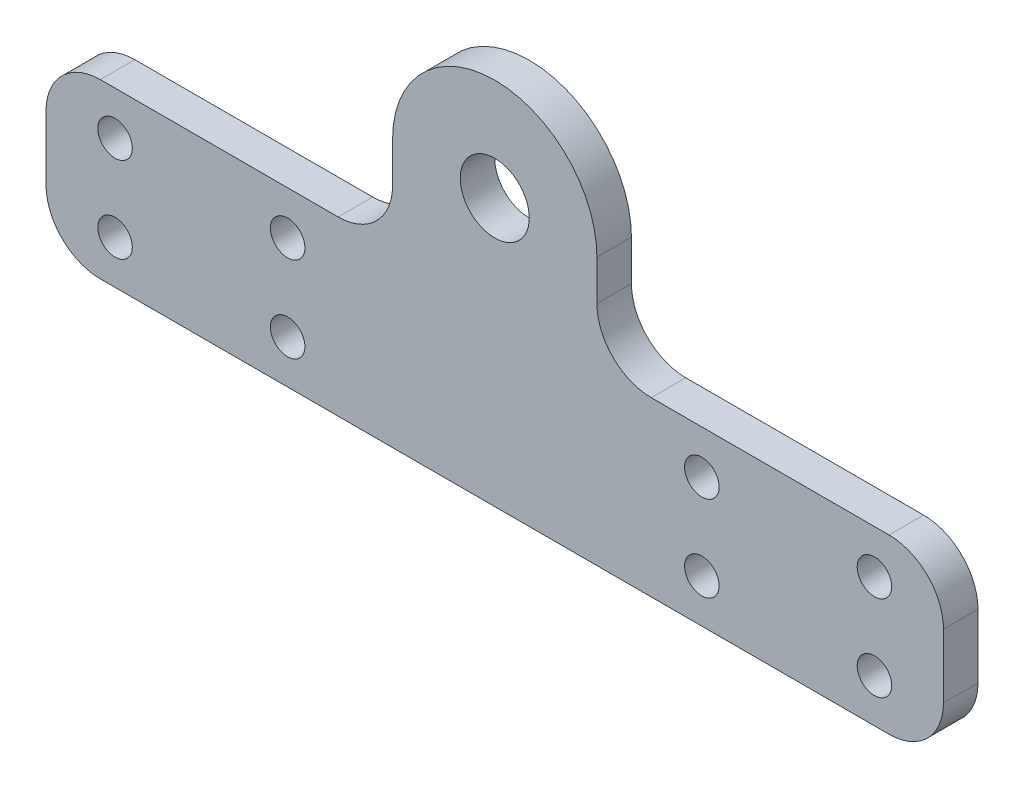
from build123d import *

# Parameters (mm, degrees)
SKETCH1_R           = 3.175
SKETCH1_R_2         = 1.5875
BOSS_EXTRUDE1_DEPTH = 3.175
FILLET1_R           = 5


with BuildPart() as part:
    # Sketch1 → Boss-Extrude1 (new body)
    with BuildSketch(Plane.XY):
        with BuildLine():
            Line((-41.275, -8.7), (-14.398, -8.7))
            ThreePointArc((-14.398, -8.7), (-10.862466094, -7.235533906), (-9.398, -3.7))
            Line((-9.398, -3.7), (-9.398, 0))
            ThreePointArc((-9.398, 0), (0, 9.398), (9.398, 0))
            Line((9.398, 0), (9.398, -3.7))
            ThreePointArc((9.398, -3.7), (10.862466094, -7.235533906), (14.398, -8.7))
            Line((14.398, -8.7), (41.275, -8.7))
            Line((41.275, -8.7), (41.275, -24.575))
            Line((41.275, -24.575), (-41.275, -24.575))
            Line((-41.275, -24.575), (-41.275, -8.7))
        make_face()
        Circle(SKETCH1_R, mode=Mode.SUBTRACT)
        with Locations((-34.925, -12.7)):
            Circle(SKETCH1_R_2, mode=Mode.SUBTRACT)
        with Locations((-34.925, -20.575)):
            Circle(SKETCH1_R_2, mode=Mode.SUBTRACT)
        with Locations((-19.05, -12.7)):
            Circle(SKETCH1_R_2, mode=Mode.SUBTRACT)
        with Locations((-19.05, -20.575)):
            Circle(SKETCH1_R_2, mode=Mode.SUBTRACT)
        with Locations((19.05, -20.575)):
            Circle(SKETCH1_R_2, mode=Mode.SUBTRACT)
        with Locations((19.05, -12.7)):
            Circle(SKETCH1_R_2, mode=Mode.SUBTRACT)
        with Locations((34.925, -20.575)):
            Circle(SKETCH1_R_2, mode=Mode.SUBTRACT)
        with Locations((34.925, -12.7)):
            Circle(SKETCH1_R_2, mode=Mode.SUBTRACT)
    extrude(amount=BOSS_EXTRUDE1_DEPTH)

    # Fillet1
    fillet1_edges = [part.edges().sort_by_distance(p)[0] for p in [
        (41.275, -24.575, 1.5875),
        (41.275, -8.7, 1.5875),
        (-41.275, -24.575, 1.5875),
        (-41.275, -8.7, 1.5875),
    ]]
    fillet(fillet1_edges, radius=FILLET1_R)


solid = part.part
